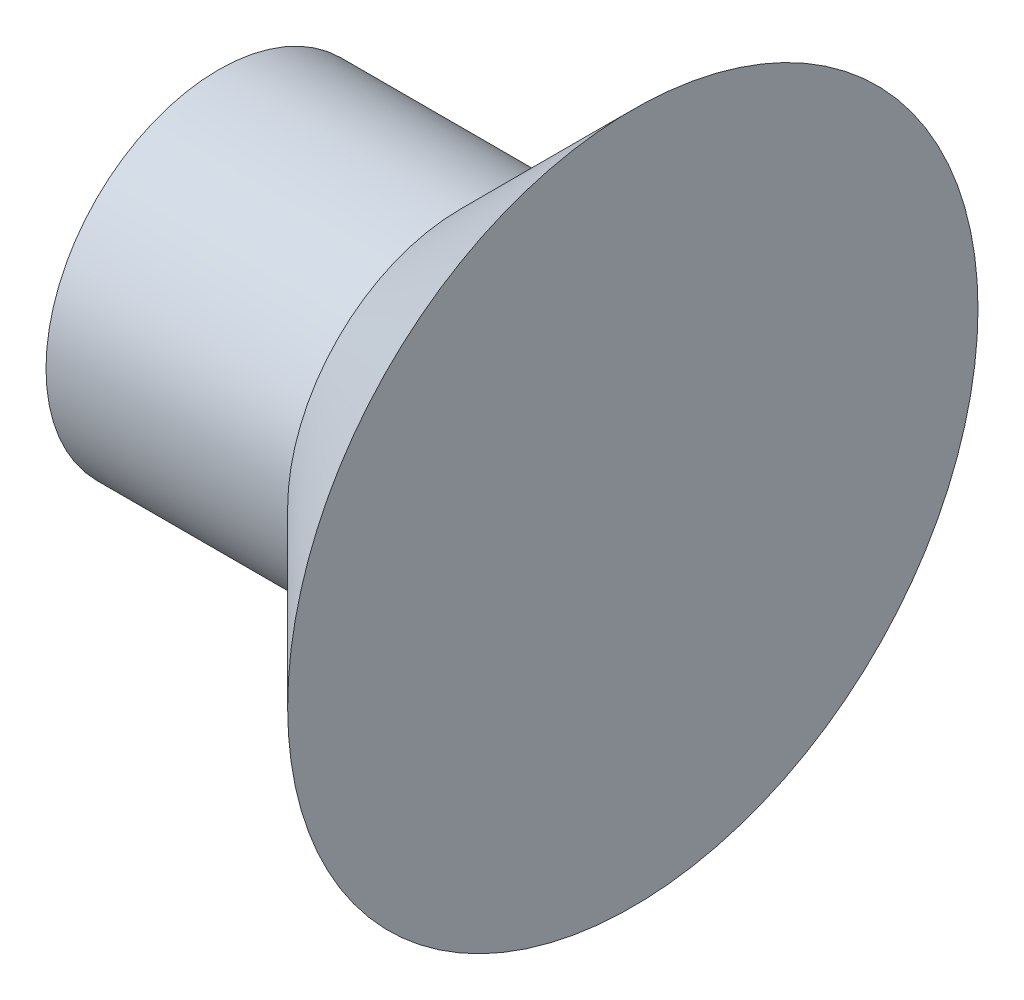
from build123d import *


with BuildPart() as part:
    # Esquisse1 → Révolution1 (revolve)
    with BuildSketch(Plane.XY, mode=Mode.PRIVATE) as r_volution1_sk:
        Polygon((0, 0), (-3, 0), (-3, 1.25), (-1.25, 1.25), (0, 2.5), align=None)
    revolve(r_volution1_sk.sketch.rotate(Axis((0, 0, 0), (1, 0, 0)), 90), axis=Axis((0, 0, 0), (1, 0, 0)))  # turned: the seam where the file's is


solid = part.part
